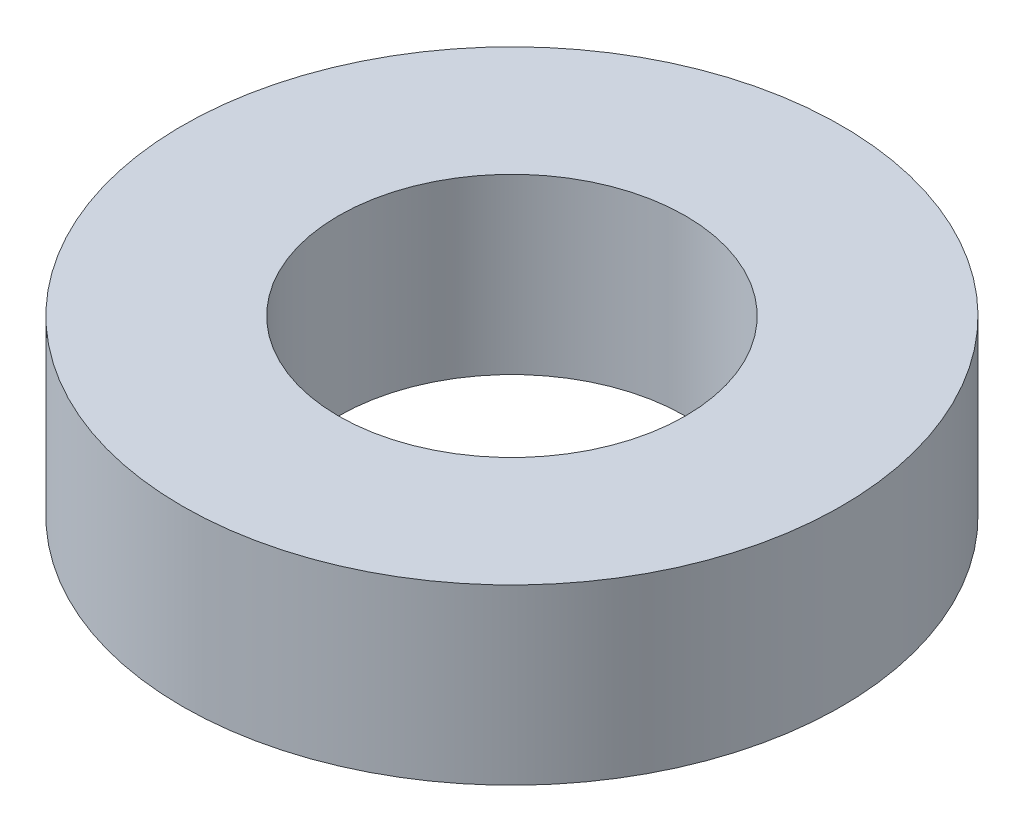
from build123d import *

# Parameters (mm, degrees)
SKETCH1_R           = 9.5
SKETCH1_R_2         = 5
BOSS_EXTRUDE1_DEPTH = 5


with BuildPart() as part:
    # Sketch1 → Boss-Extrude1 (new body)
    with BuildSketch(Plane(origin=(0, 0, 0), x_dir=(1, 0, 0), z_dir=(0, 1, 0))):
        Circle(SKETCH1_R)
        Circle(SKETCH1_R_2, mode=Mode.SUBTRACT)
    extrude(amount=BOSS_EXTRUDE1_DEPTH)


solid = part.part
